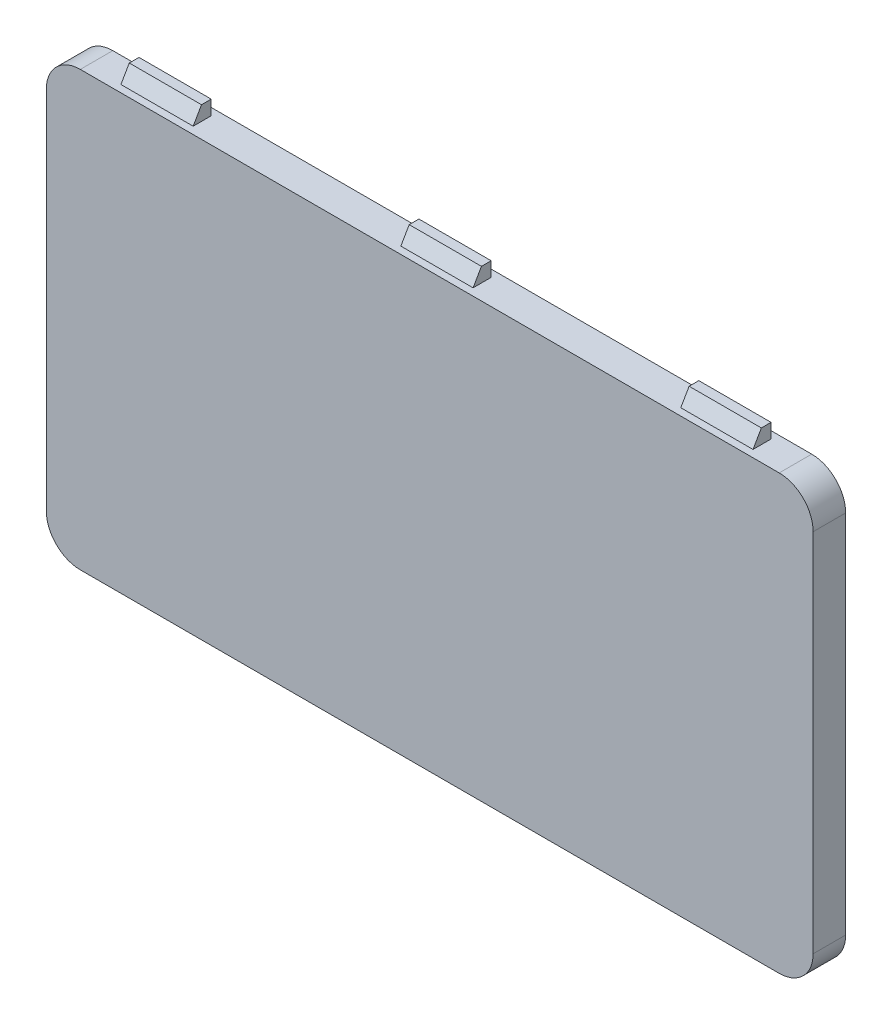
from build123d import *

# Parameters (mm, degrees)
BOSS_EXTRUDE1_DEPTH    = 1.8
LATCH_DEPTH            = 2
LPATTERN1_COUNT        = 2
LPATTERN1_PITCH        = 15.5
LPATTERN1_COPY_1_DEPTH = 2
LPATTERN2_COUNT        = 2
LPATTERN2_PITCH        = 15.5
LPATTERN2_COPY_1_DEPTH = 2


with BuildPart() as part:
    # Sketch1 → Boss-Extrude1 (new body)
    with BuildSketch(Plane.XY):
        with BuildLine():
            Line((-21.23, 10.12), (-21.23, -10.12))
            ThreePointArc((-21.23, -10.12), (-20.679360749, -11.449360749), (-19.35, -12))
            Line((-19.35, -12), (19.35, -12))
            ThreePointArc((19.35, -12), (20.679360749, -11.449360749), (21.23, -10.12))
            Line((21.23, -10.12), (21.23, 10.12))
            ThreePointArc((21.23, 10.12), (20.679360749, 11.449360749), (19.35, 12))
            Line((19.35, 12), (-19.35, 12))
            ThreePointArc((-19.35, 12), (-20.679360749, 11.449360749), (-21.23, 10.12))
        make_face()
    extrude(amount=BOSS_EXTRUDE1_DEPTH)

    # Sketch4 → Latch (add, symmetric)
    with BuildSketch(Plane(origin=(0, 0, 0), x_dir=(0, 0, -1), z_dir=(1, 0, 0))):
        Polygon((-1.4, 12), (-0.938119785, 12.8), (-0.4, 12.8), (-0.4, 12), align=None)
    latch = extrude(amount=LATCH_DEPTH, both=True)

    # Mirror1: Latch across plane
    add(latch.mirror(Plane.ZX))

    # LPattern1: Latch ×2
    with Locations(*[(i * LPATTERN1_PITCH, 0, 0) for i in range(1, LPATTERN1_COUNT)]):
        add(latch)

    # LPattern1 copy 1 sketch → LPattern1 copy 1 (add, symmetric)
    with BuildSketch(Plane(origin=(15.5, 0, 0), x_dir=(0, 0, -1), z_dir=(1, 0, 0))):
        Polygon((-1.4, -12), (-0.938119785, -12.8), (-0.4, -12.8), (-0.4, -12), align=None)
    extrude(amount=LPATTERN1_COPY_1_DEPTH, both=True)

    # LPattern2: Latch ×2
    with Locations(*[(-i * LPATTERN2_PITCH, 0, 0) for i in range(1, LPATTERN2_COUNT)]):
        add(latch)

    # LPattern2 copy 1 sketch → LPattern2 copy 1 (add, symmetric)
    with BuildSketch(Plane(origin=(-15.5, 0, 0), x_dir=(0, 0, -1), z_dir=(1, 0, 0))):
        Polygon((-1.4, -12), (-0.938119785, -12.8), (-0.4, -12.8), (-0.4, -12), align=None)
    extrude(amount=LPATTERN2_COPY_1_DEPTH, both=True)


solid = part.part
